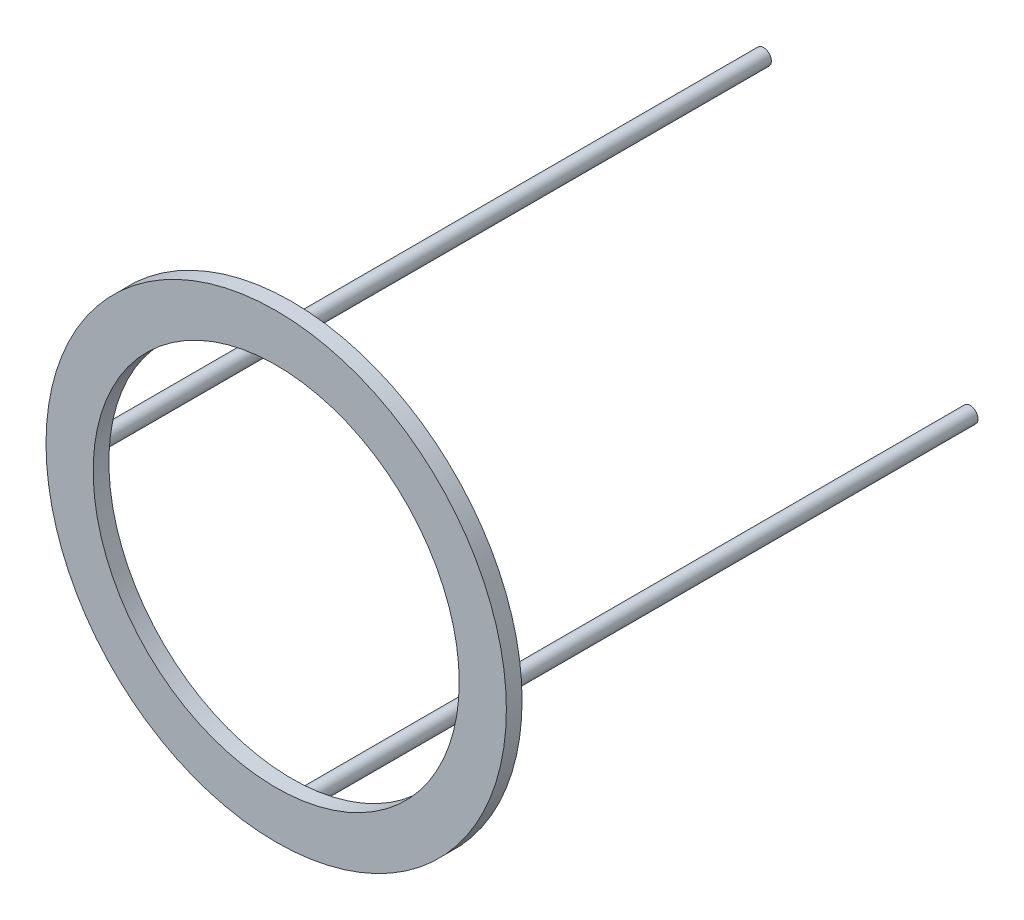
from build123d import *

# Parameters (mm, degrees)
SKETCH2_R           = 146.421356237
SKETCH2_R_2         = 116.421356237
BOSS_EXTRUDE1_DEPTH = 10
SKETCH7_R           = 5
BOSS_EXTRUDE3_DEPTH = 300


with BuildPart() as part:
    # Sketch2 → Boss-Extrude1 (new body)
    with BuildSketch(Plane.XY):
        Circle(SKETCH2_R)
        Circle(SKETCH2_R_2, mode=Mode.SUBTRACT)
    extrude(amount=BOSS_EXTRUDE1_DEPTH)

    # Sketch7 → Boss-Extrude3 (add)
    with BuildSketch(Plane(origin=(0, 0, 0), x_dir=(-1, 0, 0), z_dir=(0, 0, -1))):
        with Locations((-131.421356237, 0)):
            Circle(SKETCH7_R)
        with Locations((0, 131.421356237)):
            Circle(SKETCH7_R)
        with Locations((131.421356237, 0)):
            Circle(SKETCH7_R)
        with Locations((0, -131.421356237)):
            Circle(SKETCH7_R)
    extrude(amount=BOSS_EXTRUDE3_DEPTH)


solid = part.part
